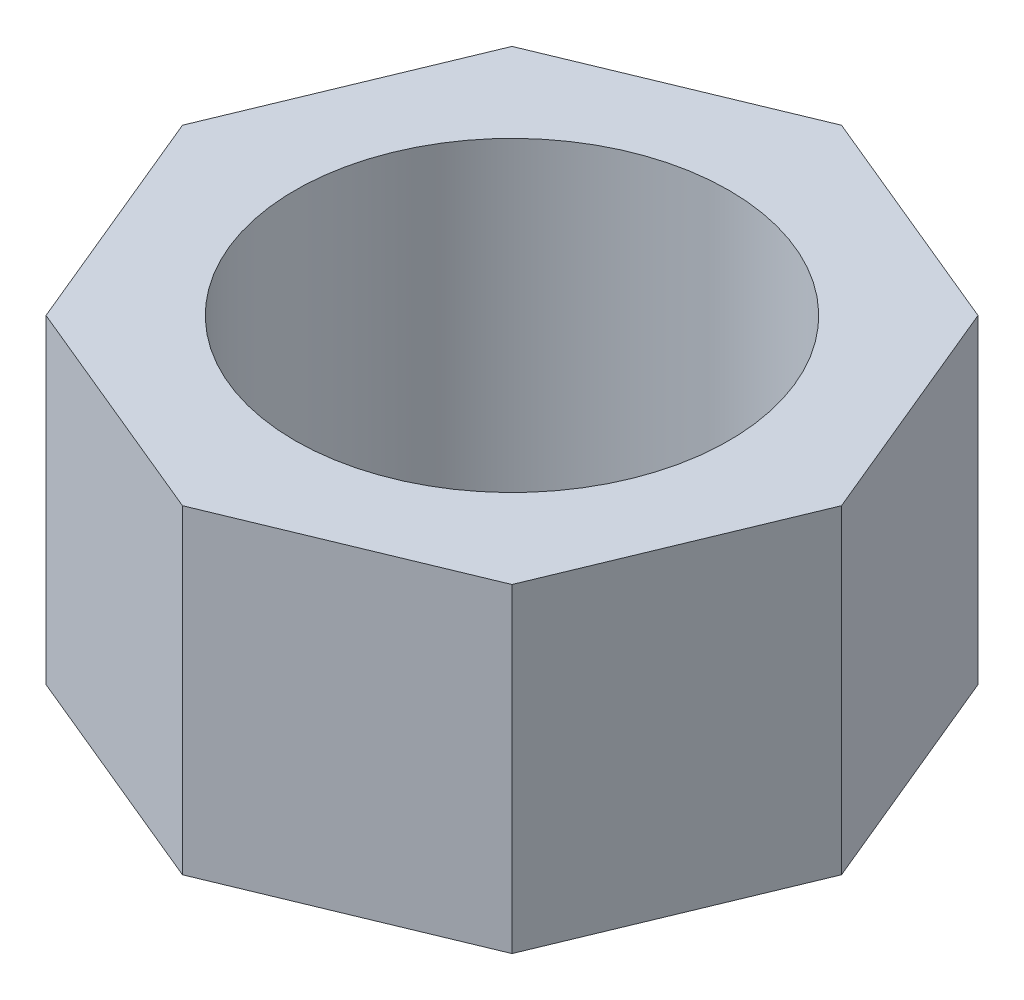
from build123d import *

# Parameters (mm, degrees)
SKETCH1_R           = 5.7
BOSS_EXTRUDE1_DEPTH = 8.4


with BuildPart() as part:
    # Sketch1 → Boss-Extrude1 (new body)
    with BuildSketch(Plane(origin=(0, 0, 0), x_dir=(1, 0, 0), z_dir=(0, 1, 0))):
        Polygon((8.659137602, 0), (6.122934918, 6.122934918), (0, 8.659137602), (-6.122934918, 6.122934918), (-8.659137602, 0), (-6.122934918, -6.122934918), (0, -8.659137602), (6.122934918, -6.122934918), align=None)
        Circle(SKETCH1_R, mode=Mode.SUBTRACT)
    extrude(amount=BOSS_EXTRUDE1_DEPTH)


solid = part.part
